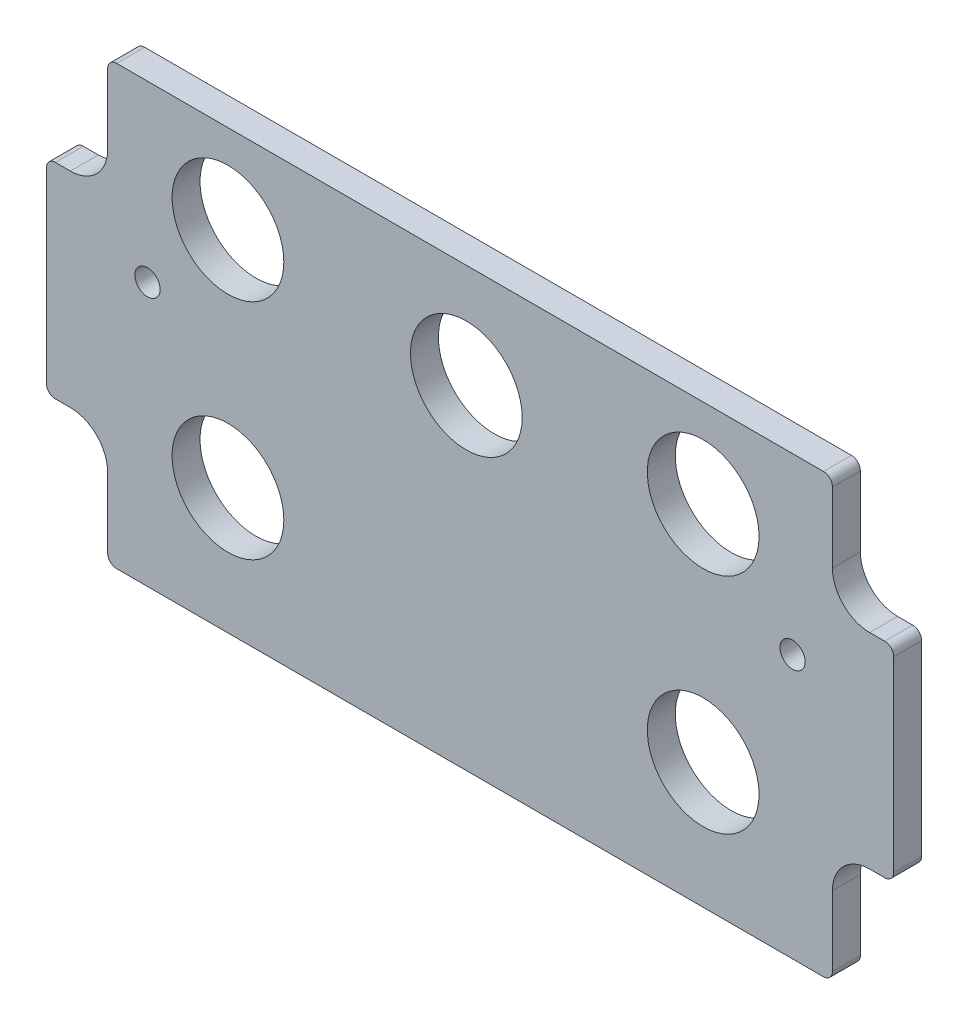
from build123d import *

# Parameters (mm, degrees)
BOSS_EXTRUDE1_DEPTH         = 4.7625
F_3_4_0_75_DIAMETER_HOLE1_D = 19.05
F_6_CLEARANCE_HOLE1_D       = 4.3053


with BuildPart() as part:
    # Sketch1 → Boss-Extrude1 (new body)
    with BuildSketch(Plane.XY):
        with BuildLine():
            Line((134.8105, 61.9125), (134.8105, 73.88225))
            ThreePointArc((134.8105, 73.88225), (134.364130735, 74.959880735), (133.2865, 75.40625))
            Line((133.2865, 75.40625), (12.7635, 75.40625))
            ThreePointArc((12.7635, 75.40625), (11.685869265, 74.959880735), (11.2395, 73.88225))
            Line((11.2395, 73.88225), (11.2395, 61.9125))
            ThreePointArc((11.2395, 61.9125), (9.379628061, 57.422371939), (4.8895, 55.5625))
            Line((4.8895, 55.5625), (2.31775, 55.5625))
            ThreePointArc((2.31775, 55.5625), (1.240119265, 55.116130735), (0.79375, 54.0385))
            Line((0.79375, 54.0385), (0.79375, 22.1615))
            ThreePointArc((0.79375, 22.1615), (1.240119265, 21.083869265), (2.31775, 20.6375))
            Line((2.31775, 20.6375), (4.8895, 20.6375))
            ThreePointArc((4.8895, 20.6375), (9.379628061, 18.777628061), (11.2395, 14.2875))
            Line((11.2395, 14.2875), (11.2395, 2.31775))
            ThreePointArc((11.2395, 2.31775), (11.685869265, 1.240119265), (12.7635, 0.79375))
            Line((12.7635, 0.79375), (133.2865, 0.79375))
            ThreePointArc((133.2865, 0.79375), (134.364130735, 1.240119265), (134.8105, 2.31775))
            Line((134.8105, 2.31775), (134.8105, 14.2875))
            ThreePointArc((134.8105, 14.2875), (136.670371939, 18.777628061), (141.1605, 20.6375))
            Line((141.1605, 20.6375), (143.73225, 20.6375))
            ThreePointArc((143.73225, 20.6375), (144.809880735, 21.083869265), (145.25625, 22.1615))
            Line((145.25625, 22.1615), (145.25625, 54.0385))
            ThreePointArc((145.25625, 54.0385), (144.809880735, 55.116130735), (143.73225, 55.5625))
            Line((143.73225, 55.5625), (141.1605, 55.5625))
            ThreePointArc((141.1605, 55.5625), (136.670371939, 57.422371939), (134.8105, 61.9125))
        make_face()
    extrude(amount=BOSS_EXTRUDE1_DEPTH)

    # 3/4 (0.75) Diameter Hole1 (through all)
    with Locations(Plane.XY.offset(4.7625)):
        with Locations((31.75, 60.325), (72.39, 57.658), (112.776, 60.325), (112.776, 22.225), (31.75, 22.225)):
            Hole(F_3_4_0_75_DIAMETER_HOLE1_D / 2)

    # #6 Clearance Hole1 (through all)
    with Locations(Plane.XY.offset(4.7625)):
        with Locations((18.034, 45.72), (128.016, 45.72)):
            Hole(F_6_CLEARANCE_HOLE1_D / 2)


solid = part.part
